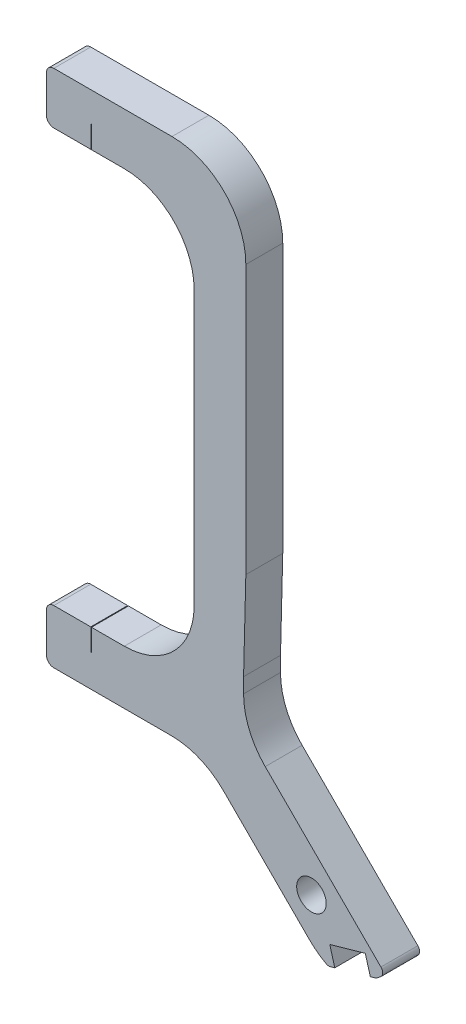
from build123d import *

# Parameters (mm, degrees)
SKETCH1_R           = 2
BOSS_EXTRUDE1_DEPTH = 5
SKETCH2_W           = 0.1
SKETCH2_H           = 5
CUT_EXTRUDE1_DEPTH  = 3
SKETCH3_W           = 0.1
SKETCH3_H           = 5
CUT_EXTRUDE2_DEPTH  = 3
SKETCH4_W           = 5
SKETCH4_H           = 5
CUT_EXTRUDE3_DEPTH  = 2.5
FILLET1_R           = 10


with BuildPart() as part:
    # Sketch1 → Boss-Extrude1 (new body)
    with BuildSketch(Plane.XY):
        with BuildLine():
            Line((1, 0), (17, 0))
            ThreePointArc((17, 0), (24.071067812, -2.928932188), (27, -10))
            Line((27, -10), (27, -10.164726931))
            Line((27, -10.164726931), (27, -46.377180563))
            Line((27, -46.377180563), (26.694646109, -58.493944172))
            Line((26.694646109, -58.493944172), (26.694646109, -64.399649032))
            Line((26.694646109, -64.399649032), (26.694646109, -64.648499642))
            Line((26.694646109, -64.648499642), (45.291824906, -83.245678439))
            ThreePointArc((45.291824906, -83.245678439), (45.524094874, -83.868523218), (45.205420336, -84.451902592))
            Line((45.205420336, -84.451902592), (44.749875598, -84.792762343))
            ThreePointArc((44.749875598, -84.792762343), (44.625232832, -84.869323208), (44.488733304, -84.921908985))
            Line((44.488733304, -84.921908985), (38.461997774, -86.629961997))
            ThreePointArc((38.461997774, -86.629961997), (38.153804902, -86.655191857), (37.859066622, -86.561657168))
            ThreePointArc((37.859066622, -86.561657168), (36.668252624, -85.793859327), (35.597906198, -84.865468229))
            Line((35.597906198, -84.865468229), (21.037791859, -70.305353891))
            Line((21.037791859, -70.305353891), (16.801941123, -70.305353891))
            Line((16.801941123, -70.305353891), (1, -70.305353891))
            ThreePointArc((1, -70.305353891), (0.292893219, -70.012460672), (0, -69.305353891))
            Line((0, -69.305353891), (0, -64))
            ThreePointArc((0, -64), (0.292893219, -63.292893219), (1, -63))
            Line((1, -63), (10.539737479, -63))
            ThreePointArc((10.539737479, -63), (17.229153259, -60.229153259), (20, -53.539737479))
            Line((20, -53.539737479), (20, -16.460262521))
            ThreePointArc((20, -16.460262521), (17.229153259, -9.770846741), (10.539737479, -7))
            Line((10.539737479, -7), (1, -7))
            ThreePointArc((1, -7), (0.292893219, -6.707106781), (0, -6))
            Line((0, -6), (0, -1))
            ThreePointArc((0, -1), (0.292893219, -0.292893219), (1, 0))
        make_face()
        with Locations((35.887034264, -79.497742046)):
            Circle(SKETCH1_R, mode=Mode.SUBTRACT)
    extrude(amount=BOSS_EXTRUDE1_DEPTH)

    # Sketch2 → Cut-Extrude1 (cut)
    with BuildSketch(Plane(origin=(0, -63, 0), x_dir=(1, 0, 0), z_dir=(0, 1, 0))):
        with Locations((6.05, -2.5)):
            Rectangle(SKETCH2_W, SKETCH2_H)
    extrude(amount=-CUT_EXTRUDE1_DEPTH, mode=Mode.SUBTRACT)

    # Sketch3 → Cut-Extrude2 (cut)
    with BuildSketch(Plane.XZ.offset(7)):
        with Locations((6.05, 2.5)):
            Rectangle(SKETCH3_W, SKETCH3_H)
    extrude(amount=-CUT_EXTRUDE2_DEPTH, mode=Mode.SUBTRACT)

    # Sketch4 → Cut-Extrude3 (cut)
    with BuildSketch(Plane(origin=(25.586241806, -90.279113957, 0), x_dir=(0.962106712, 0.272673201, 0), z_dir=(0.272673201, -0.962106712, 0))):
        with Locations((16.490695772, 2.5)):
            Rectangle(SKETCH4_W, SKETCH4_H)
    extrude(amount=-CUT_EXTRUDE3_DEPTH, mode=Mode.SUBTRACT)

    # Fillet1
    fillet1_edges = [part.edges().sort_by_distance(p)[0] for p in [
        (26.694646109, -64.648499642, 2.5),
        (21.037791859, -70.305353891, 2.5),
    ]]
    fillet(fillet1_edges, radius=FILLET1_R)


solid = part.part
